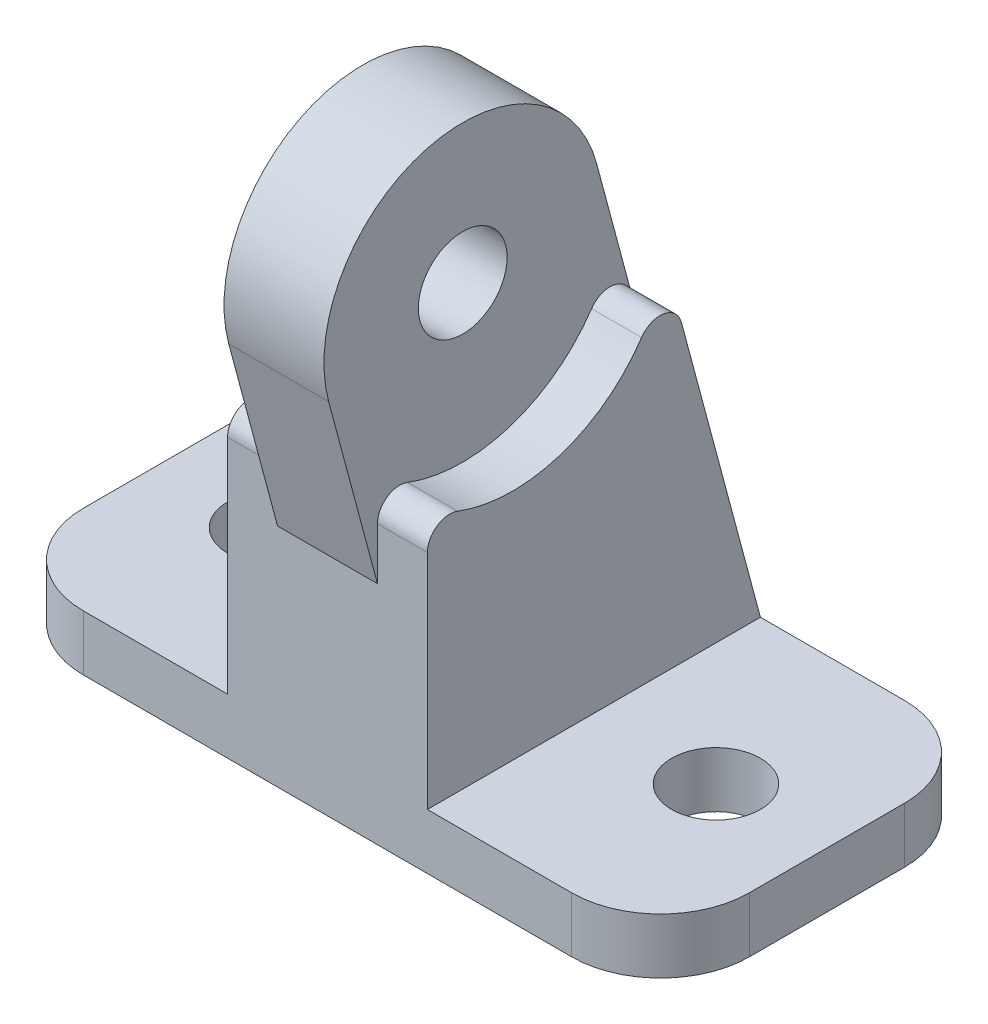
from build123d import *

# Parameters (mm, degrees)
SKETCH1_R           = 3.999999999999999
BOSS_EXTRUDE1_DEPTH = 5
SKETCH2_R           = 4.000000000000002
BOSS_EXTRUDE2_DEPTH = 4.5
BOSS_EXTRUDE3_DEPTH = 9
FILLET1_R           = 2


with BuildPart() as part:
    # Sketch1 → Boss-Extrude1 (new body)
    with BuildSketch(Plane(origin=(0, 0, 0), x_dir=(1, 0, 0), z_dir=(0, 1, 0))):
        with BuildLine():
            Line((-21.999999999999943, -15), (21.999999999999943, -15))
            ThreePointArc((21.999999999999943, -15), (27.65685424949238, -12.65685424949238), (30, -6.999999999999942))
            Line((30, -6.999999999999942), (30, 6.999999999999942))
            ThreePointArc((30, 6.999999999999942), (27.65685424949238, 12.65685424949238), (21.999999999999943, 15))
            Line((21.999999999999943, 15), (-21.999999999999943, 15))
            ThreePointArc((-21.999999999999943, 15), (-27.656854249492383, 12.65685424949238), (-30.000000000000004, 6.999999999999942))
            Line((-30.000000000000004, 6.999999999999942), (-30.000000000000004, -6.999999999999942))
            ThreePointArc((-30.000000000000004, -6.999999999999942), (-27.656854249492383, -12.656854249492383), (-21.999999999999943, -15))
        make_face()
        with Locations((-20.000000000000004, 0)):
            Circle(SKETCH1_R, mode=Mode.SUBTRACT)
        with Locations((19.99999999999999, 0)):
            Circle(SKETCH1_R, mode=Mode.SUBTRACT)
    extrude(amount=BOSS_EXTRUDE1_DEPTH)

    # Sketch2 → Boss-Extrude2 (add, symmetric)
    with BuildSketch(Plane(origin=(0, 0, 0), x_dir=(0, 0, -1), z_dir=(1, 0, 0))):
        with BuildLine():
            Line((-15, 20.368941598159466), (-15, 5))
            Line((-15, 5), (15, 5))
            Line((15.000000000000002, 5), (4.754898838397974, 43.23523806378153))
            ThreePointArc((4.754898838397979, 43.23523806378153), (-10.554412053996897, 52.07407282861335), (-19.39324681882872, 36.76476193621848))
            Line((-19.39324681882872, 36.76476193621847), (-15, 20.368941598159466))
        make_face()
        with Locations((-7.31917399021537, 40)):
            Circle(SKETCH2_R, mode=Mode.SUBTRACT)
    extrude(amount=BOSS_EXTRUDE2_DEPTH, both=True)

    # Sketch2_4 → Boss-Extrude3 (add, symmetric)
    with BuildSketch(Plane(origin=(0, 0, 0), x_dir=(0, 0, -1), z_dir=(1, 0, 0))):
        with BuildLine():
            Line((-15, 20.368941598159466), (-15, 5))
            Line((-15, 5), (15, 5))
            Line((15.000000000000004, 5), (6.386690828752239, 37.145307448395535))
            ThreePointArc((6.386690828752242, 37.145307448395535), (-1.9659638137879103, 27.06388231319019), (-15, 28.295090269147053))
            Line((-15, 28.295090269147053), (-15, 20.368941598159466))
        make_face()
    extrude(amount=BOSS_EXTRUDE3_DEPTH, both=True)

    # Fillet1
    fillet1_edges = [part.edges().sort_by_distance(p)[0] for p in [
        (-6.75, 37.145307448395535, -6.38669082875224),
        (-6.75, 28.295090269147053, 15),
        (6.75, 37.145307448395535, -6.38669082875224),
        (6.75, 28.295090269147053, 15),
    ]]
    fillet(fillet1_edges, radius=FILLET1_R)


solid = part.part
